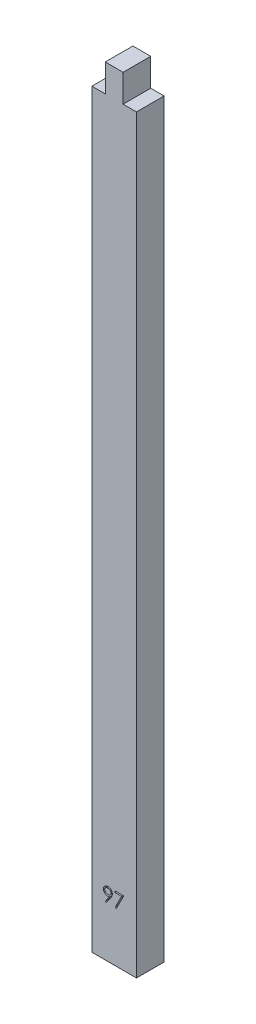
from build123d import *

# Parameters (mm, degrees)
BOSS_EXTRUDE1_DEPTH = 6.2
CUT_EXTRUDE1_DEPTH  = 1


with BuildPart() as part:
    # Sketch1 → Boss-Extrude1 (new body)
    with BuildSketch(Plane.XY):
        Polygon((0, 0), (0, 168.21), (3, 168.21), (3, 174.41), (7, 174.41), (7, 168.21), (10, 168.21), (10, 0), align=None)
    extrude(amount=BOSS_EXTRUDE1_DEPTH)

    # Sketch4 → Cut-Extrude1 (cut)
    with BuildSketch(Plane.XY.offset(6.2)):
        with BuildLine():
            Line((3.246096477, 11.250682627), (3.018402166, 11.409051017))
            Line((3.018402166, 11.409051017), (3.901194634, 12.699530784))
            add(Edge.make_bspline(
                [(3.901194634, 12.699530784), (3.844869467, 12.692642791), (3.733962072, 12.679079948), (3.62225913, 12.67658834), (3.567285379, 12.675362114)],
                knots=[0, 0, 0, 0, 0.000170115, 0.000334967, 0.000334967, 0.000334967, 0.000334967], degree=3))
            add(Edge.make_bspline(
                [(3.567285379, 12.675362114), (3.533955093, 12.676215805), (3.468530656, 12.677891525), (3.3723448, 12.691173737), (3.279920041, 12.711629925), (3.191501411, 12.742154152), (3.106756575, 12.780089242), (3.025870535, 12.827130962), (2.948952177, 12.882472383), (2.876827598, 12.945820883), (2.81123052, 13.01537883), (2.752789386, 13.088998592), (2.704219931, 13.167535365), (2.663873314, 13.249387065), (2.633274974, 13.335730147), (2.610993243, 13.425582103), (2.597275107, 13.519572664), (2.595643071, 13.583549033), (2.594814426, 13.616032186)],
                knots=[0, 0, 0, 0, 9.9954e-05, 0.000196201, 0.000290782, 0.000383503, 0.000476303, 0.000568919, 0.000663705, 0.000760153, 0.000856434, 0.000950205, 0.001041624, 0.001132931, 0.001223461, 0.001315861, 0.001410305, 0.001507717, 0.001507717, 0.001507717, 0.001507717], degree=3))
            add(Edge.make_bspline(
                [(2.594814426, 13.616032186), (2.596387806, 13.66045375), (2.599476032, 13.747644268), (2.624330401, 13.875037758), (2.665206566, 13.995494123), (2.722200879, 14.108696656), (2.793987377, 14.213016941), (2.880264455, 14.307004751), (2.980507337, 14.389323296), (3.092432454, 14.460084138), (3.213402694, 14.516993743), (3.34010212, 14.558939394), (3.471559929, 14.583612544), (3.560612029, 14.586865432), (3.605446437, 14.58850314)],
                knots=[0, 0, 0, 0, 0.000133185, 0.000261414, 0.000387724, 0.00051373, 0.000640399, 0.00076644, 0.000895188, 0.001028407, 0.001162697, 0.001295241, 0.001427846, 0.0015623, 0.0015623, 0.0015623, 0.0015623], degree=3))
            add(Edge.make_bspline(
                [(3.605446437, 14.58850314), (3.649432361, 14.586842921), (3.736344399, 14.583562484), (3.864150855, 14.55953774), (3.986561635, 14.519045901), (4.102898159, 14.46308919), (4.210611768, 14.392948081), (4.307472683, 14.309368906), (4.391270493, 14.212299606), (4.461867871, 14.104087904), (4.518537122, 13.987822143), (4.559424121, 13.866461013), (4.584593379, 13.740877316), (4.587765048, 13.655792329), (4.589365708, 13.612852098)],
                knots=[0, 0, 0, 0, 0.000131915, 0.000260652, 0.000388569, 0.000517718, 0.000646848, 0.000773094, 0.000900237, 0.001030248, 0.001159674, 0.001287189, 0.001413545, 0.001542287, 0.001542287, 0.001542287, 0.001542287], degree=3))
            add(Edge.make_bspline(
                [(4.589365708, 13.612852098), (4.588296723, 13.579520252), (4.586128553, 13.51191494), (4.570946332, 13.409198844), (4.545165164, 13.304468086), (4.515908266, 13.215820638), (4.487666942, 13.142606544), (4.46108663, 13.084774754), (4.431593462, 13.023904322), (4.397195725, 12.960633523), (4.360218499, 12.894155795), (4.318436155, 12.825137902), (4.272801815, 12.75348723), (4.24029914, 12.705184514), (4.223655572, 12.680450255)],
                knots=[0, 0, 0, 0, 9.9984e-05, 0.000202793, 0.000310776, 0.000423207, 0.000482616, 0.000546097, 0.000614079, 0.0006855, 0.000762103, 0.000842274, 0.000927493, 0.001016928, 0.001016928, 0.001016928, 0.001016928], degree=3))
            Line((4.223655572, 12.680450255), (3.246096477, 11.250682627))
        make_face()
        with BuildLine():
            add(Edge.make_bspline(
                [(3.620074842, 13.00100314), (3.64532427, 13.001692917), (3.69447632, 13.003035677), (3.76648287, 13.011208347), (3.834449826, 13.025699034), (3.898558745, 13.046490487), (3.959452435, 13.071579037), (4.016163675, 13.103521339), (4.068739929, 13.141636429), (4.117533263, 13.184462657), (4.160862034, 13.23204283), (4.199454641, 13.281842348), (4.232257441, 13.334079815), (4.258168414, 13.389409418), (4.279472279, 13.446484314), (4.294184333, 13.506223622), (4.302334406, 13.5683161), (4.303723764, 13.610497025), (4.30442981, 13.631932627)],
                knots=[0, 0, 0, 0, 7.5753e-05, 0.000147465, 0.000217073, 0.000283852, 0.000349411, 0.000414338, 0.000478589, 0.000543925, 0.000608743, 0.000671332, 0.000732749, 0.000793345, 0.000854313, 0.000915245, 0.00097749, 0.001041807, 0.001041807, 0.001041807, 0.001041807], degree=3))
            add(Edge.make_bspline(
                [(4.30442981, 13.631932627), (4.303822325, 13.653377181), (4.3026252, 13.695636304), (4.293021007, 13.75782071), (4.276125268, 13.817413883), (4.253455329, 13.874742073), (4.22359197, 13.929334267), (4.187756665, 13.981875865), (4.145182229, 14.032033724), (4.096194187, 14.078628195), (4.043367128, 14.121579503), (3.987069388, 14.159485444), (3.927765, 14.191254672), (3.86581577, 14.217470166), (3.801092625, 14.237927848), (3.733633864, 14.252639315), (3.663098603, 14.260777978), (3.615218437, 14.262158554), (3.590818032, 14.262862114)],
                knots=[0, 0, 0, 0, 6.4316e-05, 0.000126743, 0.000188161, 0.000249812, 0.000311283, 0.000374438, 0.00044032, 0.000508243, 0.00057698, 0.000644365, 0.000711521, 0.0007785, 0.000845884, 0.000914871, 0.00098532, 0.001058531, 0.001058531, 0.001058531, 0.001058531], degree=3))
            add(Edge.make_bspline(
                [(3.590818032, 14.262862114), (3.566629835, 14.262157417), (3.519172793, 14.260774807), (3.449264592, 14.252654785), (3.382261961, 14.23782891), (3.317726348, 14.217479642), (3.255778959, 14.191252716), (3.196477368, 14.159483779), (3.14016646, 14.121588229), (3.087390049, 14.0785944), (3.038315505, 14.032250606), (2.996473061, 13.981656139), (2.960555745, 13.929361599), (2.930733421, 13.874734809), (2.908052566, 13.817415821), (2.89115975, 13.757820185), (2.881554771, 13.69563644), (2.880357754, 13.653377227), (2.879750323, 13.631932627)],
                knots=[0, 0, 0, 0, 7.2576e-05, 0.000142393, 0.000210758, 0.000278143, 0.000345121, 0.000412278, 0.000479663, 0.0005484, 0.000616323, 0.000681795, 0.00074495, 0.000806421, 0.000868072, 0.00092949, 0.000991917, 0.001056233, 0.001056233, 0.001056233, 0.001056233], degree=3))
            add(Edge.make_bspline(
                [(2.879750323, 13.631932627), (2.880299985, 13.610480333), (2.881384018, 13.568172481), (2.89184137, 13.506009253), (2.909329524, 13.446420677), (2.9327514, 13.38882735), (2.963595699, 13.333789308), (3.00144519, 13.281567487), (3.045809507, 13.2315699), (3.096095599, 13.184573357), (3.151130288, 13.141436741), (3.209910193, 13.103762752), (3.271423403, 13.071947034), (3.335886453, 13.046418779), (3.402821622, 13.02590677), (3.472830491, 13.011235054), (3.545681535, 13.003114069), (3.595039161, 13.001713534), (3.620074842, 13.00100314)],
                knots=[0, 0, 0, 0, 6.4316e-05, 0.000126844, 0.000188436, 0.000250326, 0.000312966, 0.000377217, 0.000443451, 0.000513196, 0.000583426, 0.000652939, 0.000722346, 0.000790847, 0.000860662, 0.000932137, 0.001005113, 0.00108023, 0.00108023, 0.00108023, 0.00108023], degree=3))
        make_face(mode=Mode.SUBTRACT)
        Polygon((5.199942631, 14.507092884), (7.153788785, 14.507092884), (5.484878528, 11.250682627), (5.238739706, 11.386154382), (6.671687423, 14.181451858), (5.199942631, 14.181451858), align=None)
    extrude(amount=-CUT_EXTRUDE1_DEPTH, mode=Mode.SUBTRACT)


solid = part.part
